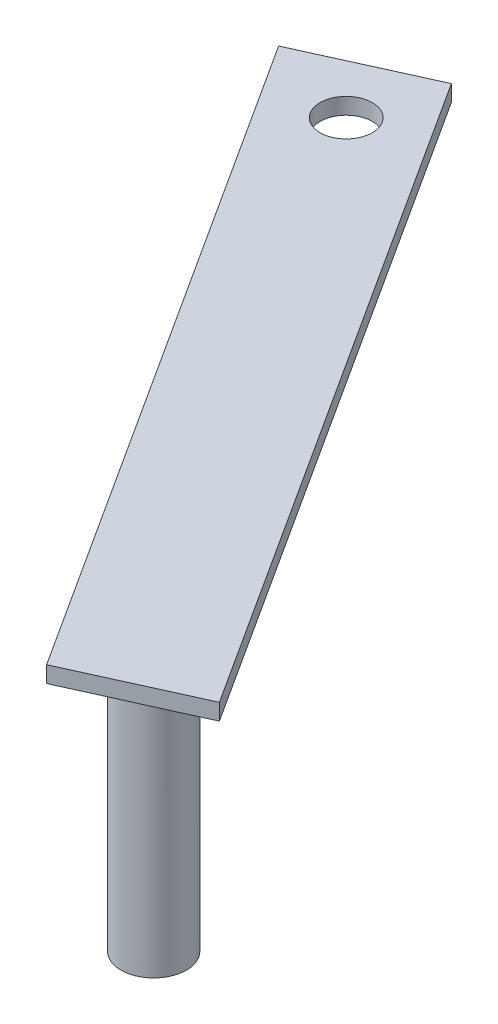
from build123d import *

# Parameters (mm, degrees)
SKETCH1_R           = 5.078298903
BOSS_EXTRUDE1_DEPTH = 3.175
SKETCH2_R           = 6.35
BOSS_EXTRUDE2_DEPTH = 53.975


with BuildPart() as part:
    # Sketch1 → Boss-Extrude1 (new body)
    with BuildSketch(Plane(origin=(0, 0, 0), x_dir=(1, 0, 0), z_dir=(0, 1, 0))):
        Polygon((-46.777175674, -53.719844845), (-128.460753109, 73.100956593), (-105.319843222, 83.572742001), (-23.636265787, -43.248059437), align=None)
        with Locations((-109.811555345, 67.600325735)):
            Circle(SKETCH1_R, mode=Mode.SUBTRACT)
    extrude(amount=BOSS_EXTRUDE1_DEPTH)

    # Sketch2 → Boss-Extrude2 (add)
    with BuildSketch(Plane(origin=(0, 3.175, 0), x_dir=(1, 0, 0), z_dir=(0, 1, 0))):
        with Locations((-42.032274904, -37.632854988)):
            Circle(SKETCH2_R)
    extrude(amount=-BOSS_EXTRUDE2_DEPTH)


solid = part.part
